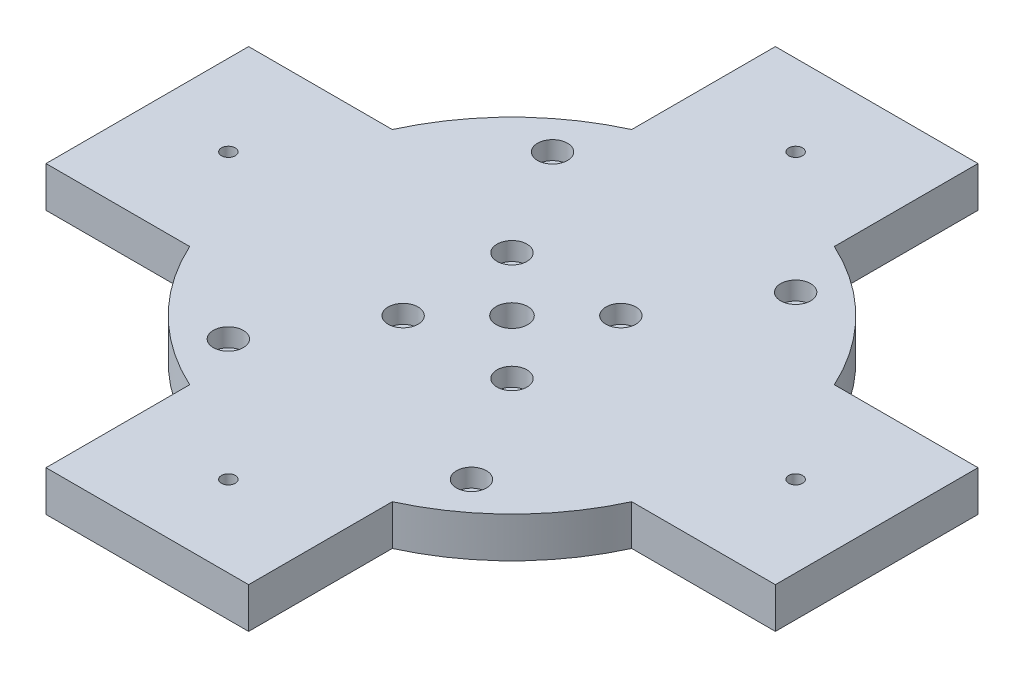
from build123d import *

# Parameters (mm, degrees)
SKETCH_1_R          = 60
EXTRUDE_1_DEPTH     = 10
SKETCH_2_R          = 1.7
SKETCH_2_R_2        = 3.925573477
CUT_EXTRUDE_1_DEPTH = 10
SKETCH_3_R          = 1.7
CUT_EXTRUDE_2_DEPTH = 10
SKETCH_4_R          = 3.7
CUT_EXTRUDE_3_DEPTH = 4.5
SKETCH_5_R          = 3.893175391
SKETCH_5_R_2        = 3.7
EXTRUDE_2_DEPTH     = 10
SKETCH_6_R          = 1.7
CUT_EXTRUDE_4_DEPTH = 10


with BuildPart() as part:
    # 草图1 → 凸台-拉伸1 (new body)
    with BuildSketch(Plane(origin=(0, 0, 0), x_dir=(1, 0, 0), z_dir=(0, 1, 0))):
        Circle(SKETCH_1_R)
    extrude(amount=EXTRUDE_1_DEPTH)

    # 草图2 → 切除-拉伸1 (cut)
    with BuildSketch(Plane(origin=(0, 10, 0), x_dir=(1, 0, 0), z_dir=(0, 1, 0))):
        with Locations((-13.435028843, 13.435028843)):
            Circle(SKETCH_2_R)
        Circle(SKETCH_2_R_2)
        with Locations((13.435028843, 13.435028843)):
            Circle(SKETCH_2_R)
        with Locations((13.435028843, -13.435028843)):
            Circle(SKETCH_2_R)
        with Locations((-13.435028843, -13.435028843)):
            Circle(SKETCH_2_R)
    extrude(amount=-CUT_EXTRUDE_1_DEPTH, mode=Mode.SUBTRACT)

    # 草图3 → 切除-拉伸2 (cut)
    with BuildSketch(Plane(origin=(0, 10, 0), x_dir=(1, 0, 0), z_dir=(0, 1, 0))):
        with Locations((-30, 40)):
            Circle(SKETCH_3_R)
        with Locations((30, 40)):
            Circle(SKETCH_3_R)
        with Locations((-30, -40)):
            Circle(SKETCH_3_R)
        with Locations((30, -40)):
            Circle(SKETCH_3_R)
    extrude(amount=-CUT_EXTRUDE_2_DEPTH, mode=Mode.SUBTRACT)

    # 草图4 → 切除-拉伸3 (cut)
    with BuildSketch(Plane(origin=(0, 10, 0), x_dir=(1, 0, 0), z_dir=(0, 1, 0))):
        with Locations((-13.435028843, 13.435028843)):
            Circle(SKETCH_4_R)
        with Locations((13.435028843, 13.435028843)):
            Circle(SKETCH_4_R)
        with Locations((13.435028843, -13.435028843)):
            Circle(SKETCH_4_R)
        with Locations((-13.435028843, -13.435028843)):
            Circle(SKETCH_4_R)
        with Locations((-30, 40)):
            Circle(SKETCH_4_R)
        with Locations((30, 40)):
            Circle(SKETCH_4_R)
        with Locations((-30, -40)):
            Circle(SKETCH_4_R)
        with Locations((30, -40)):
            Circle(SKETCH_4_R)
    extrude(amount=-CUT_EXTRUDE_3_DEPTH, mode=Mode.SUBTRACT)

    # 草图5 → 凸台-拉伸2 (add)
    with BuildSketch(Plane(origin=(0, 10, 0), x_dir=(1, 0, 0), z_dir=(0, 1, 0))):
        Polygon((25, 25), (25, 90), (-25, 90), (-25, 25), (-90, 25), (-90, -25), (-25, -25), (-25, -90), (25, -90), (25, -25), (90, -25), (90, 25), align=None)
        Circle(SKETCH_5_R, mode=Mode.SUBTRACT)
        with Locations((13.435028843, 13.435028843)):
            Circle(SKETCH_5_R_2, mode=Mode.SUBTRACT)
        with Locations((-13.435028843, 13.435028843)):
            Circle(SKETCH_5_R_2, mode=Mode.SUBTRACT)
        with Locations((-13.435028843, -13.435028843)):
            Circle(SKETCH_5_R_2, mode=Mode.SUBTRACT)
        with Locations((13.435028843, -13.435028843)):
            Circle(SKETCH_5_R_2, mode=Mode.SUBTRACT)
    extrude(amount=-EXTRUDE_2_DEPTH)

    # 草图6 → 切除-拉伸4 (cut)
    with BuildSketch(Plane.XZ):
        with Locations((0, -70)):
            Circle(SKETCH_6_R)
        with Locations((-70, 0)):
            Circle(SKETCH_6_R)
        with Locations((0, 70)):
            Circle(SKETCH_6_R)
        with Locations((70, 0)):
            Circle(SKETCH_6_R)
    extrude(amount=-CUT_EXTRUDE_4_DEPTH, mode=Mode.SUBTRACT)


solid = part.part
